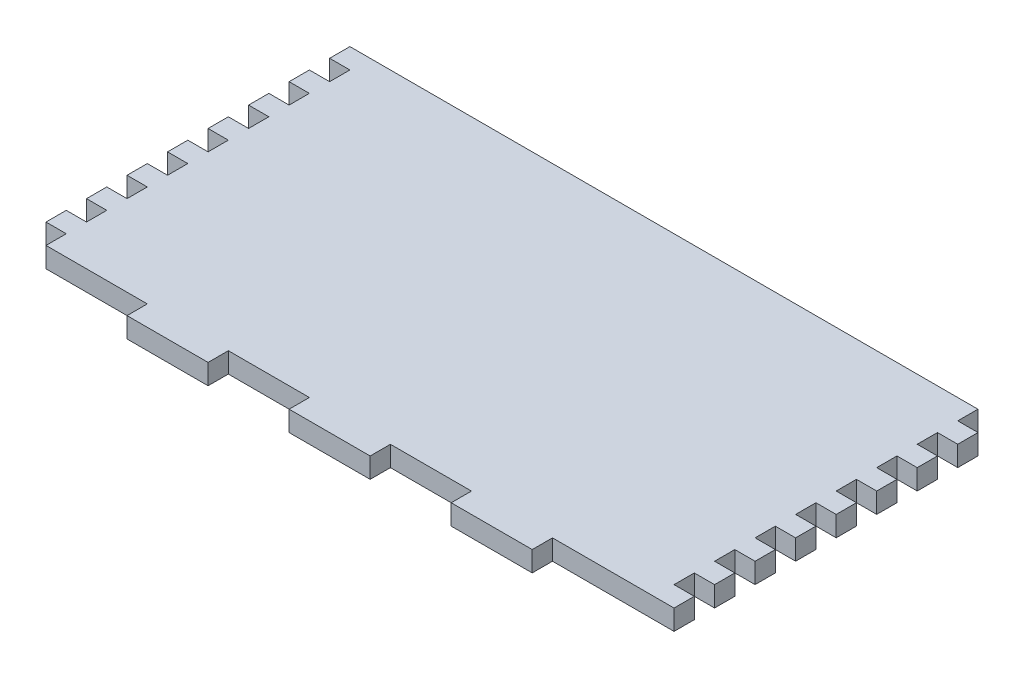
from build123d import *

# Parameters (mm, degrees)
SKETCH1_W           = 203.2
SKETCH1_H           = 107.95
BOSS_EXTRUDE1_DEPTH = 6.35
SKETCH2_W           = 38.1
SKETCH2_H           = 6.35
SKETCH2_W_2         = 25.4
CUT_EXTRUDE1_DEPTH  = 7.35
SKETCH3_W           = 6.35
SKETCH3_H           = 6.35
CUT_EXTRUDE2_DEPTH  = 7.35


with BuildPart() as part:
    # Sketch1 → Boss-Extrude1 (new body)
    with BuildSketch(Plane(origin=(0, 0, 0), x_dir=(1, 0, 0), z_dir=(0, 1, 0))):
        with Locations((16.852621149, -7.21321811)):
            Rectangle(SKETCH1_W, SKETCH1_H)
    extrude(amount=BOSS_EXTRUDE1_DEPTH)

    # Sketch2 → Cut-Extrude1 (cut, through all)
    with BuildSketch(Plane(origin=(0, 6.35, 0), x_dir=(1, 0, 0), z_dir=(0, 1, 0))):
        with Locations((99.402621149, -58.01321811)):
            Rectangle(SKETCH2_W, SKETCH2_H)
        with Locations((42.252621149, -58.01321811)):
            Rectangle(SKETCH2_W_2, SKETCH2_H)
        with Locations((-8.547378851, -58.01321811)):
            Rectangle(SKETCH2_W_2, SKETCH2_H)
        with Locations((-65.697378851, -58.01321811)):
            Rectangle(SKETCH2_W, SKETCH2_H)
    extrude(amount=-CUT_EXTRUDE1_DEPTH, mode=Mode.SUBTRACT)

    # Sketch3 → Cut-Extrude2 (cut, through all)
    with BuildSketch(Plane(origin=(0, 6.35, 0), x_dir=(1, 0, 0), z_dir=(0, 1, 0))):
        with Locations((115.277621149, -45.31321811)):
            Rectangle(SKETCH3_W, SKETCH3_H)
        with Locations((115.277621149, -32.61321811)):
            Rectangle(SKETCH3_W, SKETCH3_H)
        with Locations((115.277621149, -19.91321811)):
            Rectangle(SKETCH3_W, SKETCH3_H)
        with Locations((115.277621149, -7.194250827)):
            Rectangle(SKETCH3_W, SKETCH3_H)
        with Locations((115.277621149, 5.505749173)):
            Rectangle(SKETCH3_W, SKETCH3_H)
        with Locations((115.277621149, 18.205749173)):
            Rectangle(SKETCH3_W, SKETCH3_H)
        with Locations((115.277621149, 30.905749173)):
            Rectangle(SKETCH3_W, SKETCH3_H)
        with Locations((115.277621149, 43.605749173)):
            Rectangle(SKETCH3_W, SKETCH3_H)
        with Locations((-81.572378851, -51.66321811)):
            Rectangle(SKETCH3_W, SKETCH3_H)
        with Locations((-81.572378851, -38.96321811)):
            Rectangle(SKETCH3_W, SKETCH3_H)
        with Locations((-81.572378851, -26.26321811)):
            Rectangle(SKETCH3_W, SKETCH3_H)
        with Locations((-81.572378851, -13.56321811)):
            Rectangle(SKETCH3_W, SKETCH3_H)
        with Locations((-81.572378851, -0.86321811)):
            Rectangle(SKETCH3_W, SKETCH3_H)
        with Locations((-81.572378851, 11.83678189)):
            Rectangle(SKETCH3_W, SKETCH3_H)
        with Locations((-81.572378851, 24.53678189)):
            Rectangle(SKETCH3_W, SKETCH3_H)
        with Locations((-81.572378851, 37.23678189)):
            Rectangle(SKETCH3_W, SKETCH3_H)
    extrude(amount=-CUT_EXTRUDE2_DEPTH, mode=Mode.SUBTRACT)


solid = part.part
